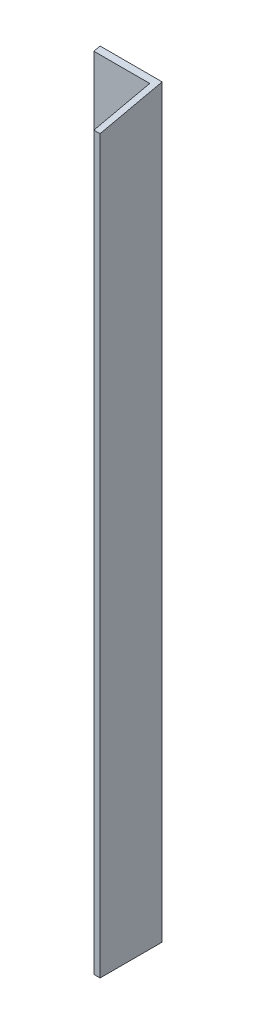
from build123d import *

# Parameters (mm, degrees)
SKETCH1_W           = 20
SKETCH1_H           = 240
BOSS_EXTRUDE1_DEPTH = 20
CUT_EXTRUDE1_DEPTH  = 20
SKETCH3_W           = 18
SKETCH3_H           = 18
CUT_EXTRUDE2_DEPTH  = 290


with BuildPart() as part:
    # Sketch1 → Boss-Extrude1 (new body)
    with BuildSketch(Plane.XY):
        with Locations((-51.462686567, -1.835820896)):
            Rectangle(SKETCH1_W, SKETCH1_H)
    extrude(amount=-BOSS_EXTRUDE1_DEPTH)

    # Sketch2 → Cut-Extrude1 (cut)
    with BuildSketch(Plane.ZY.offset(61.462686567)):
        Polygon((-20, 118.164179104), (0, 113.693649447), (0, 118.164179104), align=None)
    extrude(amount=-CUT_EXTRUDE1_DEPTH, mode=Mode.SUBTRACT)

    # Sketch3 → Cut-Extrude2 (cut)
    with BuildSketch(Plane.XZ.offset(121.835820896)):
        with Locations((-52.462686567, -9)):
            Rectangle(SKETCH3_W, SKETCH3_H)
    extrude(amount=-CUT_EXTRUDE2_DEPTH, mode=Mode.SUBTRACT)


solid = part.part
